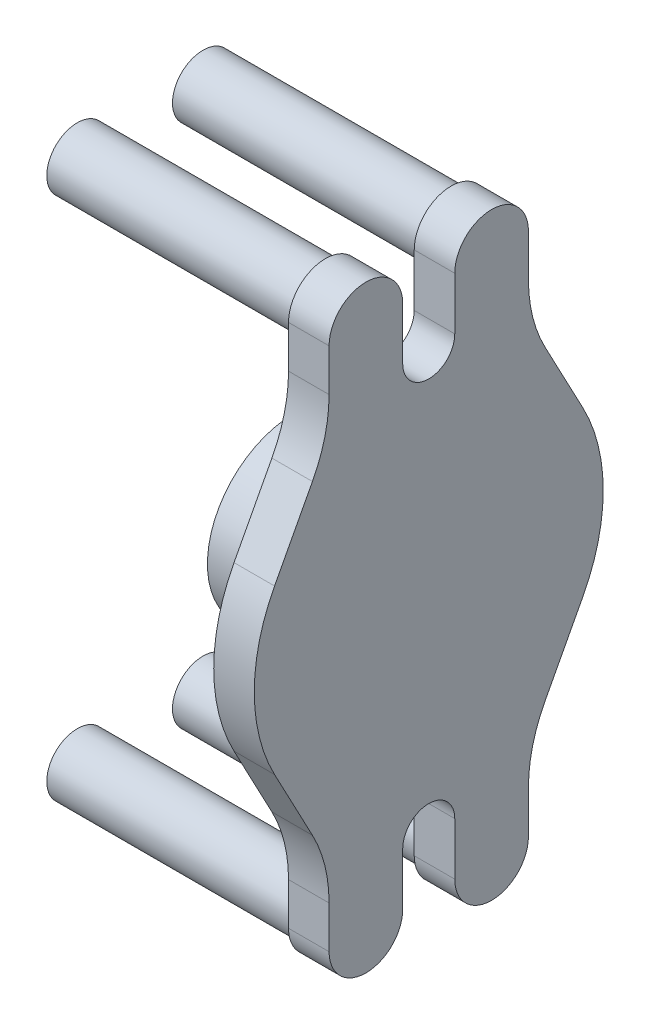
from build123d import *

# Parameters (mm, degrees)
SKETCH1_W           = 19.645
SKETCH1_H           = 18.25
SKETCH2_R           = 2.3935
CUT_EXTRUDE1_DEPTH  = 8.5725
SKETCH3_R           = 18.25
BOSS_EXTRUDE1_DEPTH = 8.5
SKETCH4_R           = 6.4
SKETCH4_R_2         = 4.75
BOSS_EXTRUDE2_DEPTH = 52


with BuildPart() as part:
    # Sketch1 → Revolve1 (revolve)
    with BuildSketch(Plane.XY):
        with Locations((18.0775, 9.125)):
            Rectangle(SKETCH1_W, SKETCH1_H)
    revolve(axis=Axis((8.255, 0, 0), (1, 0, 0)))

    # Sketch2 → Cut-Extrude1 (cut)
    with BuildSketch(Plane.ZY.offset(-8.255)):
        Circle(SKETCH2_R)
    extrude(amount=-CUT_EXTRUDE1_DEPTH, mode=Mode.SUBTRACT)


with BuildPart() as body_2:
    # Sketch3 → Boss-Extrude1 (new body)
    with BuildSketch(Plane(origin=(27.9, 0, 0), x_dir=(0, 0, -1), z_dir=(1, 0, 0))):
        with BuildLine():
            Line((-24.382347836, 32.115154563), (-32.324530318, 17.115154563))
            ThreePointArc((-32.324530318, 17.115154563), (-36.576, 0), (-32.324530318, -17.115154563))
            Line((-32.324530318, -17.115154563), (-24.382347836, -32.115154563))
            ThreePointArc((-24.382347836, -32.115154563), (-21.780072988, -38.920854003), (-20.89525, -46.153175037))
            Line((-20.89525, -46.153175037), (-20.89525, -55))
            ThreePointArc((-20.89525, -55), (-13.175, -62.72025), (-5.45475, -55))
            Line((-5.45475, -55), (-5.45475, -44))
            ThreePointArc((-5.45475, -44), (0, -38.54525), (5.45475, -44))
            Line((5.45475, -44), (5.45475, -55))
            ThreePointArc((5.45475, -55), (13.175, -62.72025), (20.89525, -55))
            Line((20.89525, -55), (20.89525, -46.153175037))
            ThreePointArc((20.89525, -46.153175037), (21.780072988, -38.920854003), (24.382347836, -32.115154563))
            Line((24.382347836, -32.115154563), (32.324530318, -17.115154563))
            ThreePointArc((32.324530318, -17.115154563), (36.576, 0), (32.324530318, 17.115154563))
            Line((32.324530318, 17.115154563), (24.382347836, 32.115154563))
            ThreePointArc((24.382347836, 32.115154563), (21.780072988, 38.920854003), (20.89525, 46.153175037))
            Line((20.89525, 46.153175037), (20.89525, 55))
            ThreePointArc((20.89525, 55), (13.175, 62.72025), (5.45475, 55))
            Line((5.45475, 55), (5.45475, 44))
            ThreePointArc((5.45475, 44), (0, 38.54525), (-5.45475, 44))
            Line((-5.45475, 44), (-5.45475, 55))
            ThreePointArc((-5.45475, 55), (-13.175, 62.72025), (-20.89525, 55))
            Line((-20.89525, 55), (-20.89525, 46.153175037))
            ThreePointArc((-20.89525, 46.153175037), (-21.780072988, 38.920854003), (-24.382347836, 32.115154563))
        make_face()
        Circle(SKETCH3_R, mode=Mode.SUBTRACT)
        Circle(SKETCH3_R)
    extrude(amount=BOSS_EXTRUDE1_DEPTH)

    # Sketch4 → Boss-Extrude2 (add)
    with BuildSketch(Plane.ZY.offset(-27.9)):
        with Locations((-13.175, 55)):
            Circle(SKETCH4_R)
        with Locations((-13.175, 55)):
            Circle(SKETCH4_R_2, mode=Mode.SUBTRACT)
        with Locations((13.175, 55)):
            Circle(SKETCH4_R)
        with Locations((13.175, 55)):
            Circle(SKETCH4_R_2, mode=Mode.SUBTRACT)
        with Locations((13.175, -55)):
            Circle(SKETCH4_R)
        with Locations((13.175, -55)):
            Circle(SKETCH4_R_2, mode=Mode.SUBTRACT)
        with Locations((-13.175, -55)):
            Circle(SKETCH4_R)
        with Locations((-13.175, -55)):
            Circle(SKETCH4_R_2, mode=Mode.SUBTRACT)
    extrude(amount=BOSS_EXTRUDE2_DEPTH)


solid = Compound([part.part, body_2.part])
